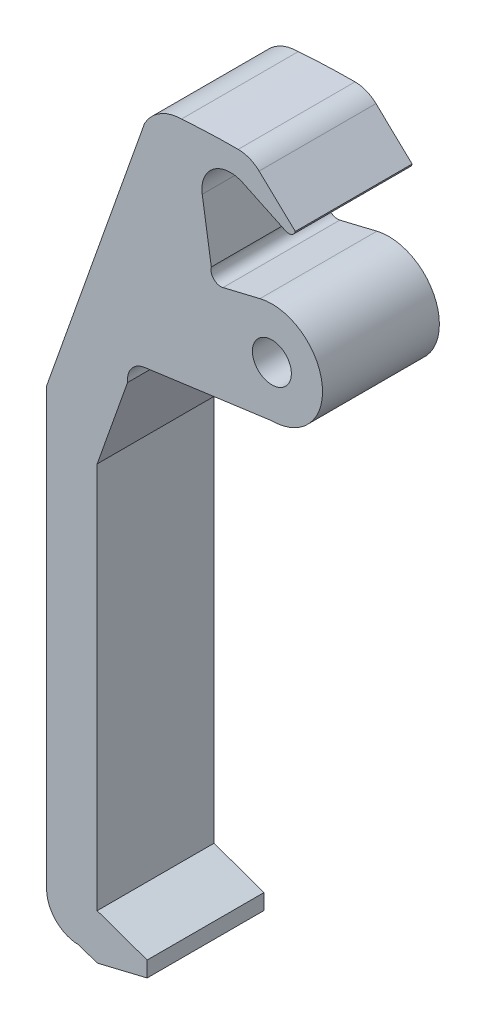
from build123d import *

# Parameters (mm, degrees)
ESQUISSE1_R        = 1
BOSS_EXTRU_1_DEPTH = 6


with BuildPart() as part:
    # Esquisse1 → Boss.-Extru.1 (new body)
    with BuildSketch(Plane.XY):
        with BuildLine():
            Line((-5.125601059, 7.752865214), (-7.025601059, 7.294584696))
            ThreePointArc((-7.025601059, 7.294584696), (-7.501583822, 7.432360963), (-7.625219148, 7.912211144))
            Line((-7.625219148, 7.912211144), (-8.091799231, 10.912211144))
            ThreePointArc((-8.091799231, 10.912211144), (-7.52044361, 12.313188257), (-6.015074536, 12.46500415))
            Line((-6.015074536, 12.46500415), (-3.79657697, 11.417824019))
            ThreePointArc((-3.79657697, 11.417824019), (-3.501096688, 11.418143301), (-3.314034571, 11.646871225))
            Line((-3.314034571, 11.646871225), (-5.170456982, 13.403293241))
            ThreePointArc((-5.170456982, 13.403293241), (-5.667222651, 13.720510456), (-6.246087907, 13.831496523))
            ThreePointArc((-6.246087907, 13.831496523), (-7.702827431, 13.804605734), (-9.157582062, 13.723970009))
            ThreePointArc((-9.157582062, 13.723970009), (-10.266440997, 13.409307705), (-11.057492389, 12.570965175))
            Line((-11.057492389, 12.570965175), (-16.083035607, -1.602809651))
            Line((-16.083035607, -1.602809651), (-16.083035607, -23.988240086))
            ThreePointArc((-16.083035607, -23.988240086), (-15.599388885, -25.155866561), (-14.43176241, -25.639513283))
            Line((-14.43176241, -25.639513283), (-13.486808234, -25.97456221))
            Line((-13.486808234, -25.97456221), (-10.920669924, -25.35560895))
            Line((-10.920669924, -25.35560895), (-10.920669924, -24.556164823))
            Line((-10.920669924, -24.556164823), (-13.486808234, -23.646298599))
            Line((-13.486808234, -23.646298599), (-13.486808234, -3.776370077))
            Line((-13.486808234, -3.776370077), (-11.927338138, 0.621876447))
            ThreePointArc((-11.927338138, 0.621876447), (-11.717055765, 1.352491988), (-11.057492389, 1.73063733))
            Line((-11.057492389, 1.73063733), (-4.515694846, 2.623090489))
            ThreePointArc((-4.515694846, 2.623090489), (-1.932742353, 5.531336315), (-5.125601059, 7.752865214))
        make_face()
        with Locations((-4.515694846, 5.224235349)):
            Circle(ESQUISSE1_R, mode=Mode.SUBTRACT)
    extrude(amount=BOSS_EXTRU_1_DEPTH)


solid = part.part
